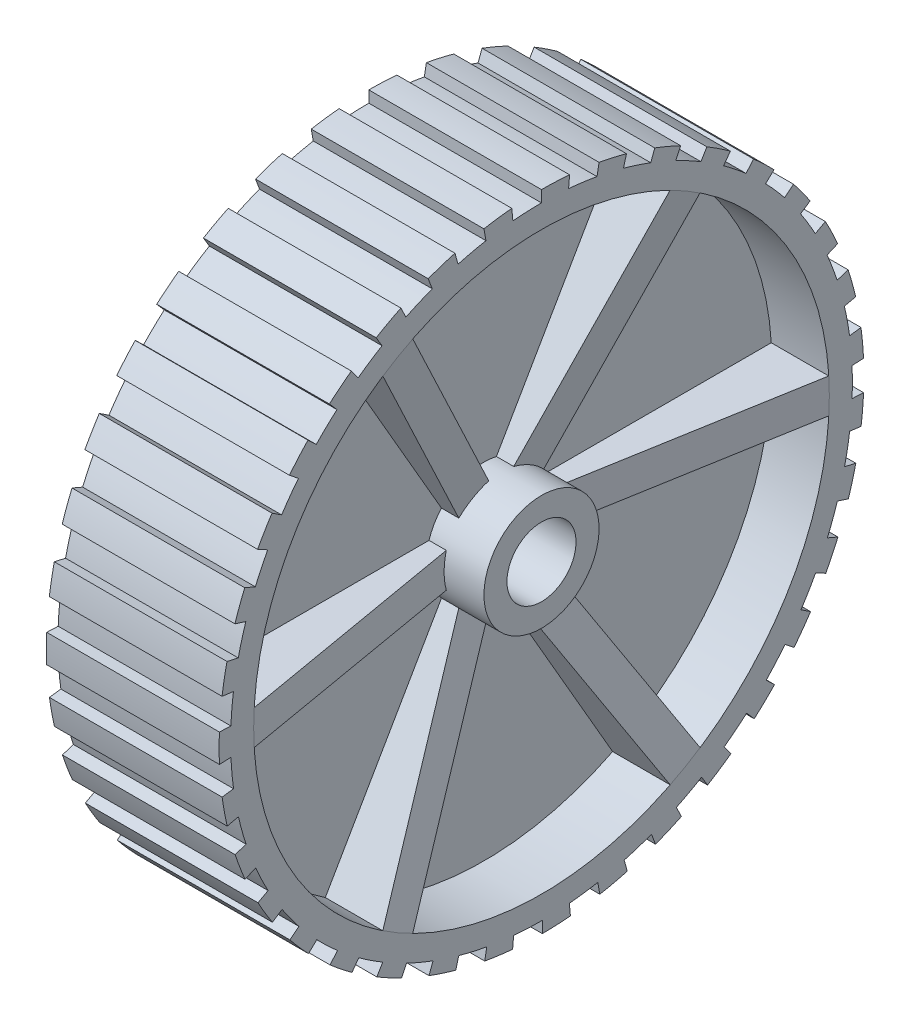
from build123d import *

# Parameters (mm, degrees)
SKETCH2_R                = 3
CUT_EXTRUDE1_DEPTH       = 11
SKETCH3_R                = 5
SKETCH3_R_2              = 3
BOSS_EXTRUDE1_DEPTH      = 5
BOSS_EXTRUDE1_DEPTH_BACK = 10
BOSS_EXTRUDE2_DEPTH      = 1.5
CIRPATTERN1_COUNT        = 6
MIRROR1_COPY_1_DEPTH     = 1.5
MIRROR1_COPY_2_DEPTH     = 1.5
MIRROR1_COPY_3_DEPTH     = 1.5
MIRROR1_COPY_4_DEPTH     = 1.5
MIRROR1_COPY_5_DEPTH     = 1.5
SKETCH6_W                = 15
SKETCH6_H                = 2
REVOLVE2_ANGLE           = 5
CIRPATTERN2_COUNT        = 35


with BuildPart() as part:
    # Sketch1 → Revolve1 (revolve)
    with BuildSketch(Plane.XY):
        Polygon((2.5, 0), (2.5, 25), (7.5, 25), (7.5, 27), (-7.5, 27), (-7.5, 25), (-2.5, 25), (-2.5, 0), align=None)
    revolve(axis=Axis((-24.671052632, 0, 0), (1, 0, 0)))

    # Sketch2 → Cut-Extrude1 (cut, through all)
    with BuildSketch(Plane.ZY.offset(2.5)):
        Circle(SKETCH2_R)
    extrude(amount=-CUT_EXTRUDE1_DEPTH, mode=Mode.SUBTRACT)

    # Sketch3 → Boss-Extrude1 (add, two sides)
    with BuildSketch(Plane.ZY.offset(2.5)) as boss_extrude1_sk:
        Circle(SKETCH3_R)
        Circle(SKETCH3_R_2, mode=Mode.SUBTRACT)
    extrude(amount=BOSS_EXTRUDE1_DEPTH)
    extrude(boss_extrude1_sk.sketch, amount=-BOSS_EXTRUDE1_DEPTH_BACK)

    # Sketch4 → Boss-Extrude2 (add, symmetric)
    with BuildSketch(Plane(origin=(0, 0, 0), x_dir=(1, 0, 0), z_dir=(0, 1, 0))):
        Polygon((2.5, 5), (2.5, 25), (7.5, 25), (3.773969647, 3.458247316), (2.5, 3.458247316), align=None)
    boss_extrude2 = extrude(amount=BOSS_EXTRUDE2_DEPTH, both=True)

    # CirPattern1: Boss-Extrude2 ×6 about axis
    cirpattern1_axis = Axis((0, 0, 0), (1, 0, 0))
    for i in range(1, CIRPATTERN1_COUNT):
        add(boss_extrude2.rotate(cirpattern1_axis, i * 360 / CIRPATTERN1_COUNT))

    # Mirror1: Boss-Extrude2 across plane
    add(boss_extrude2.mirror(Plane(origin=(0, 0, 0), x_dir=(0, 0, 1), z_dir=(1, 0, 0))))

    # Mirror1 copy 1 sketch → Mirror1 copy 1 (add, symmetric)
    with BuildSketch(Plane(origin=(0, 0, 0), x_dir=(-1, 0, 0), z_dir=(0, 0.5, 0.866025404))):
        Polygon((2.5, -5), (2.5, -25), (7.5, -25), (3.773969647, -3.458247316), (2.5, -3.458247316), align=None)
    extrude(amount=MIRROR1_COPY_1_DEPTH, both=True)

    # Mirror1 copy 2 sketch → Mirror1 copy 2 (add, symmetric)
    with BuildSketch(Plane(origin=(0, 0, 0), x_dir=(-1, 0, 0), z_dir=(0, -0.5, 0.866025404))):
        Polygon((2.5, -5), (2.5, -25), (7.5, -25), (3.773969647, -3.458247316), (2.5, -3.458247316), align=None)
    extrude(amount=MIRROR1_COPY_2_DEPTH, both=True)

    # Mirror1 copy 3 sketch → Mirror1 copy 3 (add, symmetric)
    with BuildSketch(Plane(origin=(0, 0, 0), x_dir=(-1, 0, 0), z_dir=(0, -1, 0))):
        Polygon((2.5, -5), (2.5, -25), (7.5, -25), (3.773969647, -3.458247316), (2.5, -3.458247316), align=None)
    extrude(amount=MIRROR1_COPY_3_DEPTH, both=True)

    # Mirror1 copy 4 sketch → Mirror1 copy 4 (add, symmetric)
    with BuildSketch(Plane(origin=(0, 0, 0), x_dir=(-1, 0, 0), z_dir=(0, -0.5, -0.866025404))):
        Polygon((2.5, -5), (2.5, -25), (7.5, -25), (3.773969647, -3.458247316), (2.5, -3.458247316), align=None)
    extrude(amount=MIRROR1_COPY_4_DEPTH, both=True)

    # Mirror1 copy 5 sketch → Mirror1 copy 5 (add, symmetric)
    with BuildSketch(Plane(origin=(0, 0, 0), x_dir=(-1, 0, 0), z_dir=(0, 0.5, -0.866025404))):
        Polygon((2.5, -5), (2.5, -25), (7.5, -25), (3.773969647, -3.458247316), (2.5, -3.458247316), align=None)
    extrude(amount=MIRROR1_COPY_5_DEPTH, both=True)

    # Sketch6 → Revolve2 (revolve)
    with BuildSketch(Plane.XY):
        with Locations((0, 27)):
            Rectangle(SKETCH6_W, SKETCH6_H)
    revolve2 = revolve(axis=Axis((-24.671052632, 0, 0), (-1, 0, 0)), revolution_arc=REVOLVE2_ANGLE)

    # CirPattern2: Revolve2 ×35 about axis
    cirpattern2_axis = Axis((0, 0, 0), (1, 0, 0))
    for i in range(1, CIRPATTERN2_COUNT):
        add(revolve2.rotate(cirpattern2_axis, i * 360 / CIRPATTERN2_COUNT))


solid = part.part
